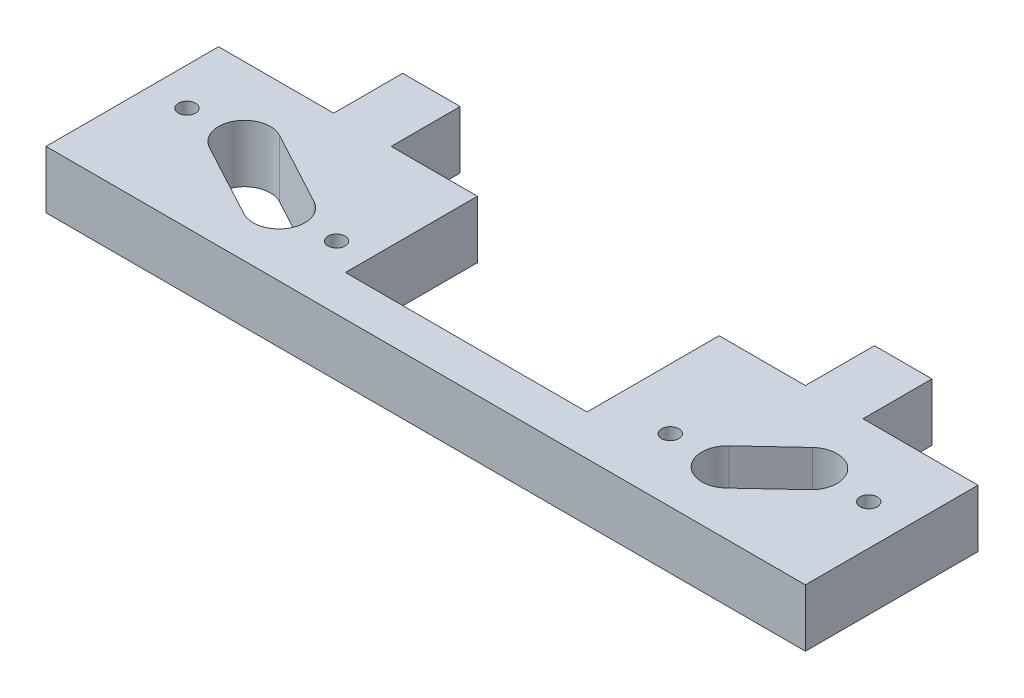
from build123d import *

# Parameters (mm, degrees)
SKETCH_1_R      = 3
EXTRUDE_1_DEPTH = 20


with BuildPart() as part:
    # 草图1 → 凸台-拉伸1 (new body)
    with BuildSketch(Plane(origin=(0, 0, 0), x_dir=(1, 0, 0), z_dir=(0, 1, 0))):
        Polygon((0, 0), (264, 0), (264, 60), (224, 60), (224, 84), (204, 84), (204, 60), (174, 60), (174, 14.075760101), (90, 14.075760101), (90, 60), (60, 60), (60, 84), (40, 84), (40, 60), (0, 60), align=None)
        with Locations((13, 36)):
            Circle(SKETCH_1_R, mode=Mode.SUBTRACT)
        with Locations((79, 22)):
            Circle(SKETCH_1_R, mode=Mode.SUBTRACT)
        with Locations((195, 22)):
            Circle(SKETCH_1_R, mode=Mode.SUBTRACT)
        with Locations((250, 36)):
            Circle(SKETCH_1_R, mode=Mode.SUBTRACT)
        with BuildLine():
            Line((37.266898407, 43.924239899), (63.266898407, 29.924239899))
            ThreePointArc((63.266898407, 29.924239899), (66.924239899, 17.733101593), (54.733101593, 14.075760101))
            Line((54.733101593, 14.075760101), (28.733101593, 28.075760101))
            ThreePointArc((28.733101593, 28.075760101), (25.075760101, 40.266898407), (37.266898407, 43.924239899))
        make_face(mode=Mode.SUBTRACT)
        with BuildLine():
            Line((208.859135747, 28.579497414), (223.859135747, 42.579497414))
            ThreePointArc((223.859135747, 42.579497414), (236.579497414, 42.140864253), (236.140864253, 29.420502586))
            Line((236.140864253, 29.420502586), (221.140864253, 15.420502586))
            ThreePointArc((221.140864253, 15.420502586), (208.420502586, 15.859135747), (208.859135747, 28.579497414))
        make_face(mode=Mode.SUBTRACT)
    extrude(amount=EXTRUDE_1_DEPTH)


solid = part.part
